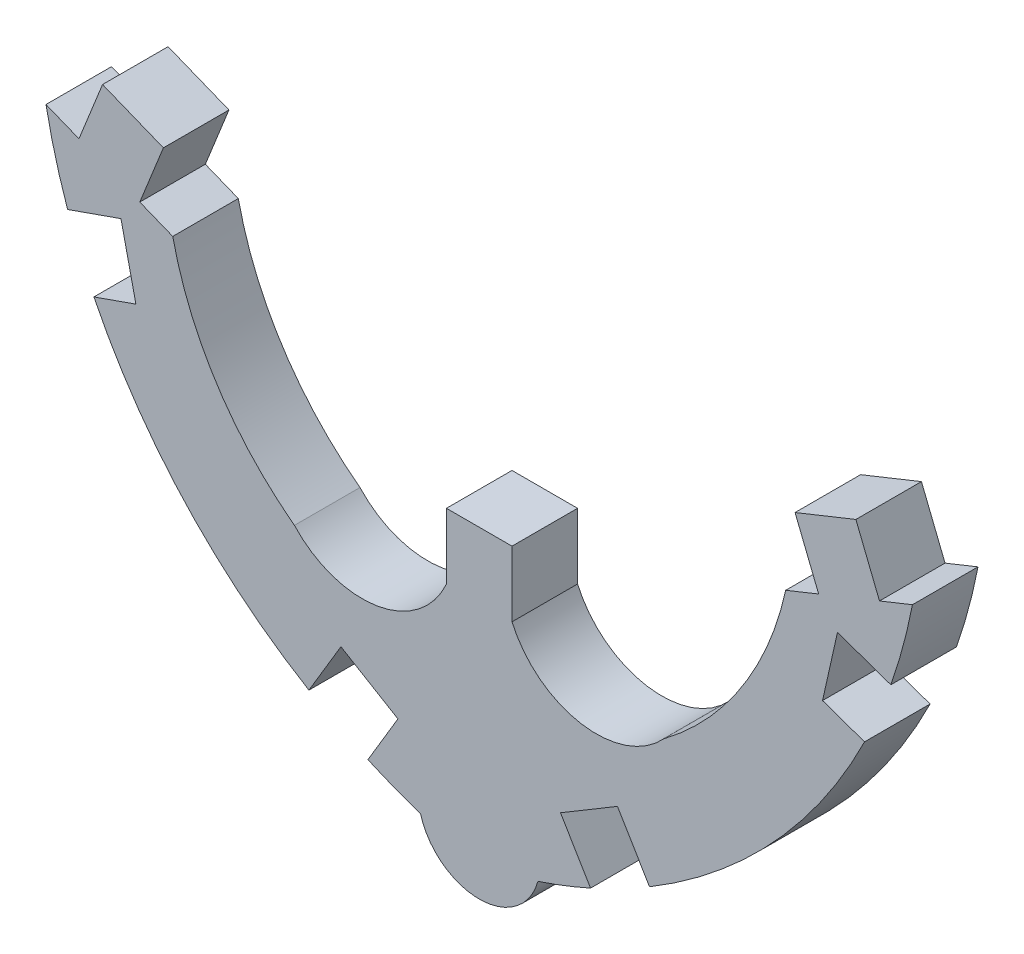
from build123d import *

# Parameters (mm, degrees)
BOSS_EXTRUDE1_DEPTH = 1.524


with BuildPart() as part:
    # Sketch1 → Boss-Extrude1 (new body)
    with BuildSketch(Plane.XY):
        with BuildLine():
            Line((106.800157748, 0), (106.800157748, -1.524))
            ThreePointArc((106.800157748, -1.524), (105.191459449, -2.771684776), (103.266120199, -2.110098583))
            ThreePointArc((103.266120199, -2.110098583), (101.457479492, -0.162046547), (100.437603623, 2.292732701))
            Line((100.437603623, 2.292732701), (99.671504405, 2.600209915))
            Line((99.671504405, 2.600209915), (100.220071172, 3.966999231))
            Line((100.220071172, 3.966999231), (98.805734154, 4.534649474))
            Line((98.805734154, 4.534649474), (98.257167386, 3.167860158))
            Line((98.257167386, 3.167860158), (97.491068168, 3.475337373))
            ThreePointArc((97.491068168, 3.475337373), (97.707736418, 2.534285361), (97.993480897, 1.611856983))
            Line((97.993480897, 1.611856983), (99.233794217, 2.047797072))
            Line((99.233794217, 2.047797072), (99.580941947, 0.500608663))
            Line((99.580941947, 0.500608663), (98.60492848, 0.15756357))
            ThreePointArc((98.60492848, 0.15756357), (100.713257844, -2.911730159), (103.603390941, -5.259654218))
            Line((103.603390941, -5.259654218), (104.347526725, -4.013018416))
            Line((104.347526725, -4.013018416), (105.672752741, -4.804065888))
            Line((105.672752741, -4.804065888), (104.974997158, -5.973001868))
            ThreePointArc((104.974997158, -5.973001868), (105.580159309, -6.225365098), (106.197246416, -6.446977219))
            ThreePointArc((106.197246416, -6.446977219), (107.562157749, -7.48677465), (108.927069081, -6.446977219))
            ThreePointArc((108.927069081, -6.446977219), (109.544156188, -6.225365098), (110.14931834, -5.973001868))
            Line((110.14931834, -5.973001868), (109.451562757, -4.804065888))
            Line((109.451562757, -4.804065888), (110.776788773, -4.013018416))
            Line((110.776788773, -4.013018416), (111.520924556, -5.259654218))
            ThreePointArc((111.520924556, -5.259654218), (114.411057653, -2.911730159), (116.519387018, 0.15756357))
            Line((116.519387018, 0.15756357), (115.543373551, 0.500608663))
            Line((115.543373551, 0.500608663), (115.89052128, 2.047797072))
            Line((115.89052128, 2.047797072), (117.130834601, 1.611856983))
            ThreePointArc((117.130834601, 1.611856983), (117.41657908, 2.534285361), (117.63324733, 3.475337373))
            Line((117.63324733, 3.475337373), (116.867148112, 3.167860158))
            Line((116.867148112, 3.167860158), (116.318581344, 4.534649474))
            Line((116.318581344, 4.534649474), (114.904244325, 3.966999231))
            Line((114.904244325, 3.966999231), (115.452811093, 2.600209915))
            Line((115.452811093, 2.600209915), (114.686711874, 2.292732701))
            ThreePointArc((114.686711874, 2.292732701), (113.666836006, -0.162046547), (111.858195299, -2.110098583))
            ThreePointArc((111.858195299, -2.110098583), (109.932856049, -2.771684776), (108.32415775, -1.524))
            Line((108.32415775, -1.524), (108.32415775, 0))
            Line((108.32415775, 0), (106.800157748, 0))
        make_face()
    extrude(amount=BOSS_EXTRUDE1_DEPTH)


solid = part.part
